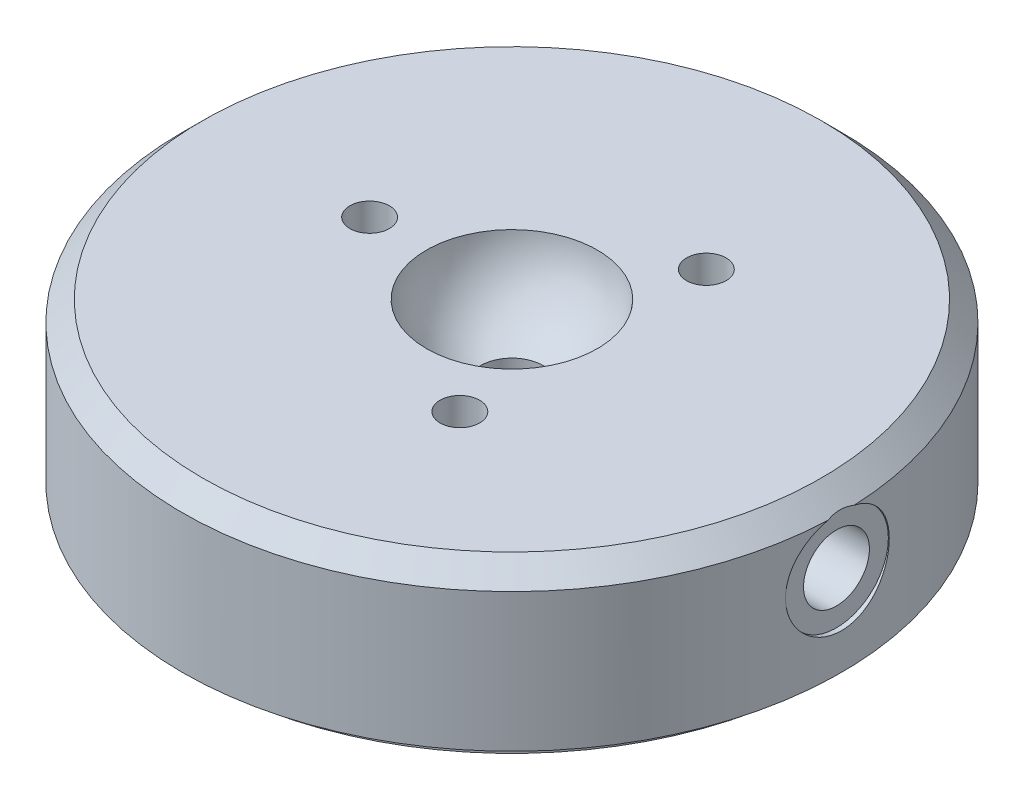
from build123d import *

# Parameters (mm, degrees)
SKETCH1_R                          = 25
EXTRUDE1_DEPTH                     = 12.0142
CHAMFER1_SIZE                      = 1.524
F_3_16_0_1875_DIAMETER_HOLE1_D     = 4.7625
F_3_16_0_1875_DIAMETER_HOLE1_DEPTH = 6.2484
SKETCH5_R                          = 23.8062
EXTRUDE2_DEPTH                     = 0.98552
M5X0_8_TAPPED_HOLE1_D              = 4.2
M5X0_8_TAPPED_HOLE1_DEPTH          = 18.542
M5X0_8_TAPPED_HOLE1_CBORE_D        = 5
M5X0_8_TAPPED_HOLE1_CBORE_DEPTH    = 7.62
M5X0_8_TAPPED_HOLE1_TIP            = 1.2618073
CIRPATTERN1_COUNT                  = 3
SKETCH10_R                         = 3.937
CUT_EXTRUDE3_DEPTH                 = 0.381


with BuildPart() as part:
    # Sketch1 → Extrude1 (new body)
    with BuildSketch(Plane(origin=(0, 0, 0), x_dir=(1, 0, 0), z_dir=(0, 1, 0))):
        with Locations(Location((0, 0, 0), (0, 0, 270))):  # turned: the seam where the file's is
            Circle(SKETCH1_R)
    extrude(amount=EXTRUDE1_DEPTH)

    # Chamfer1
    chamfer1_edges = [part.edges().sort_by_distance(p)[0] for p in [
        (0, 12.0142, -25),
    ]]
    chamfer(chamfer1_edges, length=CHAMFER1_SIZE)

    # Sketch2 → Cut-Revolve1 (revolve, cut)
    with BuildSketch(Plane.XY):
        with BuildLine():
            Line((0, 19.0246), (0, 6.0198))
            ThreePointArc((0, 6.0198), (-6.5024, 12.5222), (0, 19.0246))
        make_face()
    revolve(axis=Axis((0, 19.0246, 0), (0, -1, 0)), mode=Mode.SUBTRACT)

    # 3_16 _0.1875_ Diameter Hole1
    with Locations(Plane(origin=(0, 12.0142, 0), x_dir=(-1, 0, 0), z_dir=(0, 1, 0))):
        with Locations((0, 0)):
            Hole(F_3_16_0_1875_DIAMETER_HOLE1_D / 2, depth=F_3_16_0_1875_DIAMETER_HOLE1_DEPTH)

    # Sketch5 → Extrude2 (add)
    with BuildSketch(Plane.XZ):
        with Locations(Location((0, 0, 0), (0, 0, 90))):  # turned: the seam where the file's is
            Circle(SKETCH5_R)
    extrude(amount=EXTRUDE2_DEPTH)

    # M5x0.8 Tapped Hole1
    with Locations(Plane(origin=(25, 6.6802, 0), x_dir=(0, 0, 1), z_dir=(1, 0, 0))):
        with Locations((0, 0)):
            CounterBoreHole(M5X0_8_TAPPED_HOLE1_D / 2, M5X0_8_TAPPED_HOLE1_CBORE_D / 2, M5X0_8_TAPPED_HOLE1_CBORE_DEPTH, depth=M5X0_8_TAPPED_HOLE1_DEPTH)
            with Locations((0, 0, -(M5X0_8_TAPPED_HOLE1_DEPTH + M5X0_8_TAPPED_HOLE1_TIP / 2))):  # 118° drill point
                Cone(0, M5X0_8_TAPPED_HOLE1_D / 2, M5X0_8_TAPPED_HOLE1_TIP, mode=Mode.SUBTRACT)

    # Sketch8 → M3x0.5 Tapped Hole1 (revolve, cut)
    with BuildSketch(Plane(origin=(-10.795, 12.0142, 0), x_dir=(0, 0, 1), z_dir=(1, 0, 0))):
        Polygon((0, 0), (0, 5.553072774), (1.25, 4.801997), (1.25, 3.302), (1.5, 3.302), (1.5, 0), align=None)
    m3x0_5_tapped_hole1 = revolve(axis=Axis((-10.795, 18.3642, 0), (0, -1, 0)), mode=Mode.SUBTRACT)

    # CirPattern1: M3x0.5 Tapped Hole1 ×3 about axis
    cirpattern1_axis = Axis((0, 0, 0), (0, 1, 0))
    for i in range(1, CIRPATTERN1_COUNT):
        add(m3x0_5_tapped_hole1.rotate(cirpattern1_axis, i * 360 / CIRPATTERN1_COUNT), mode=Mode.SUBTRACT)

    # Sketch10 → Cut-Extrude3 (cut)
    with BuildSketch(Plane(origin=(25, 5.2451, 0), x_dir=(0, 0, 1), z_dir=(1, 0, 0))):
        with Locations(Location((0, -1.4351, 0), (0, 0, 180))):  # turned: the seam where the file's is
            Circle(SKETCH10_R)
    extrude(amount=-CUT_EXTRUDE3_DEPTH, mode=Mode.SUBTRACT)


solid = part.part
